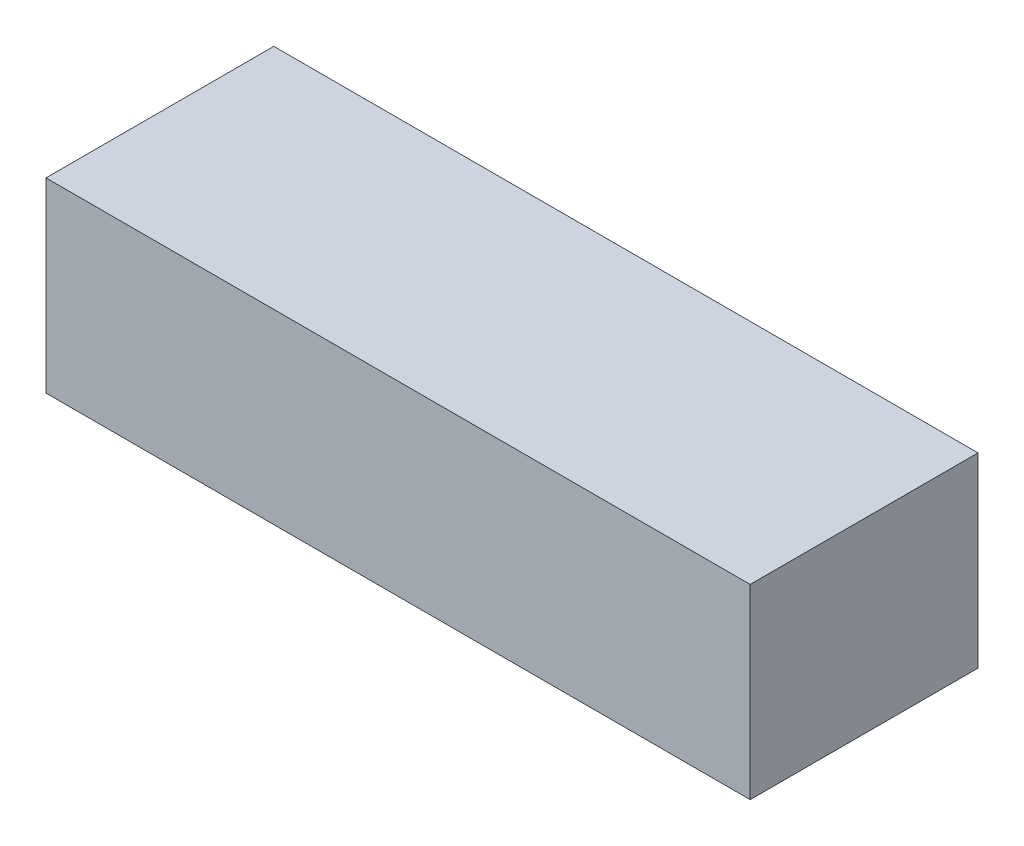
from build123d import *

# Parameters (mm, degrees)
SKETCH1_W           = 102
SKETCH1_H           = 33
BOSS_EXTRUDE1_DEPTH = 27


with BuildPart() as part:
    # Sketch1 → Boss-Extrude1 (new body)
    with BuildSketch(Plane(origin=(0, 0, 0), x_dir=(1, 0, 0), z_dir=(0, 1, 0))):
        with Locations((51, 16.5)):
            Rectangle(SKETCH1_W, SKETCH1_H)
    extrude(amount=BOSS_EXTRUDE1_DEPTH)


solid = part.part
